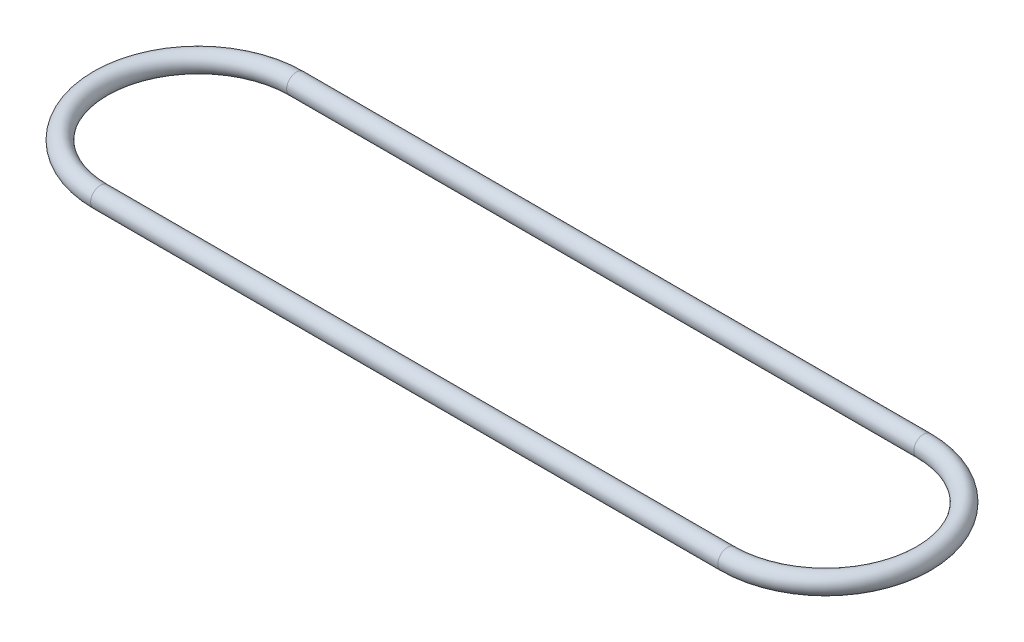
from build123d import *

# Parameters (mm, degrees)
SKETCH2_R = 3.175


with BuildPart() as part:
    # Sweep1: sweep along a path in Sketch1
    with BuildLine(Plane(origin=(0, 0, 0), x_dir=(1, 0, 0), z_dir=(0, 1, 0))) as sweep1_path:
        Line((0, 31.75), (203.2, 31.75))
        ThreePointArc((203.2, 31.75), (234.95, 0), (203.2, -31.75))
        Line((203.2, -31.75), (0, -31.75))
        ThreePointArc((0, -31.75), (-31.75, 0), (0, 31.75))
    # Sketch2 → Sweep1 (sweep)
    with BuildSketch(Plane(origin=(0, 0, 0), x_dir=(0, 0, -1), z_dir=(1, 0, 0))):
        with Locations((-31.75, 0)):
            Circle(SKETCH2_R)
    sweep(path=sweep1_path.line)


solid = part.part
